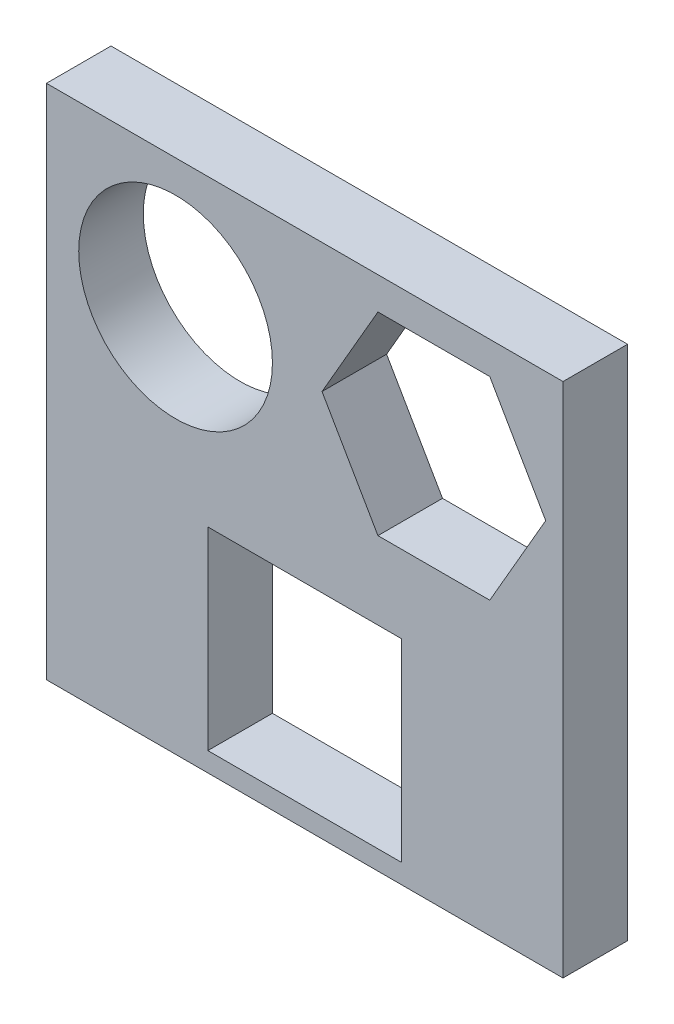
from build123d import *

# Parameters (mm, degrees)
SKETCH1_W           = 80
SKETCH1_H           = 80
SKETCH1_R           = 15
SKETCH1_W_2         = 30
SKETCH1_H_2         = 30
BOSS_EXTRUDE1_DEPTH = 10


with BuildPart() as part:
    # Sketch1 → Boss-Extrude1 (new body)
    with BuildSketch(Plane.XY):
        Rectangle(SKETCH1_W, SKETCH1_H)
        with Locations((-20, 20)):
            Circle(SKETCH1_R, mode=Mode.SUBTRACT)
        Polygon((11.339745962, 35), (2.679491924, 20), (11.339745962, 5), (28.660254038, 5), (37.320508076, 20), (28.660254038, 35), align=None, mode=Mode.SUBTRACT)
        with Locations((0, -22)):
            Rectangle(SKETCH1_W_2, SKETCH1_H_2, mode=Mode.SUBTRACT)
    extrude(amount=-BOSS_EXTRUDE1_DEPTH)


solid = part.part
